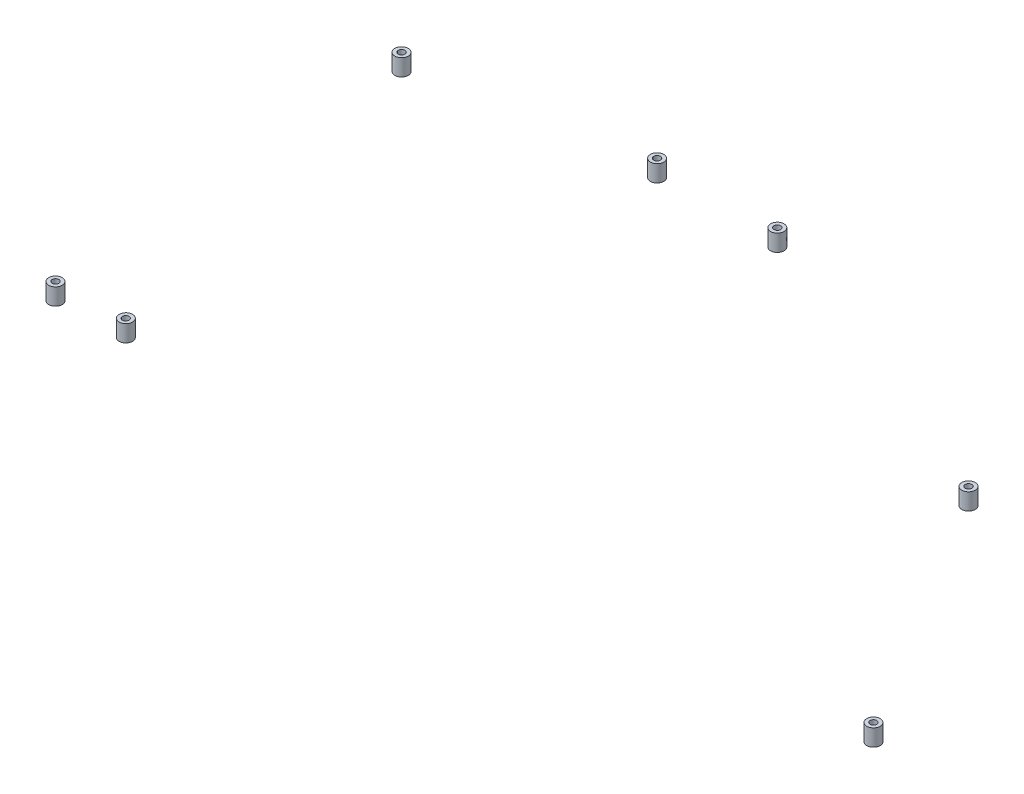
from build123d import *

# Parameters (mm, degrees)
SZKIC1_R                      = 4
SZKIC1_R_2                    = 2
DODANIE_WYCI_GNI_CIE1_DEPTH   = 10
DODANIE_WYCI_GNI_CIE1_2_DEPTH = 10
DODANIE_WYCI_GNI_CIE1_3_DEPTH = 10
SZKIC1_R_3                    = 3.999999999
DODANIE_WYCI_GNI_CIE1_4_DEPTH = 10
DODANIE_WYCI_GNI_CIE1_5_DEPTH = 10
DODANIE_WYCI_GNI_CIE1_6_DEPTH = 10
DODANIE_WYCI_GNI_CIE1_7_DEPTH = 10


with BuildPart() as part:
    # Szkic1 → Dodanie-wyciągnięcie1 (new body)
    with BuildSketch(Plane(origin=(0, 455.3, 0), x_dir=(1, 0, 0), z_dir=(0, 1, 0))):
        with Locations((-557.500474948, -428.076388532)):
            Circle(SZKIC1_R)
        with Locations((-557.500474948, -428.045174827)):
            Circle(SZKIC1_R_2, mode=Mode.SUBTRACT)
    extrude(amount=-DODANIE_WYCI_GNI_CIE1_DEPTH)


with BuildPart() as body_2:
    # Szkic1 → Dodanie-wyci_gni_cie1 2 (new body)
    with BuildSketch(Plane(origin=(0, 455.3, 0), x_dir=(1, 0, 0), z_dir=(0, 1, 0))):
        with Locations((-517.500474948, -426.079389265)):
            Circle(SZKIC1_R)
        with Locations((-517.500474948, -426.174740182)):
            Circle(SZKIC1_R_2, mode=Mode.SUBTRACT)
    extrude(amount=-DODANIE_WYCI_GNI_CIE1_2_DEPTH)


with BuildPart() as body_3:
    # Szkic1 → Dodanie-wyci_gni_cie1 3 (new body)
    with BuildSketch(Plane(origin=(0, 455.3, 0), x_dir=(1, 0, 0), z_dir=(0, 1, 0))):
        with Locations((-85.513533731, -411.920534849)):
            Circle(SZKIC1_R)
        with Locations((-85.513533731, -411.920534849)):
            Circle(SZKIC1_R_2, mode=Mode.SUBTRACT)
    extrude(amount=-DODANIE_WYCI_GNI_CIE1_3_DEPTH)


with BuildPart() as body_4:
    # Szkic1 → Dodanie-wyci_gni_cie1 4 (new body)
    with BuildSketch(Plane(origin=(0, 455.3, 0), x_dir=(1, 0, 0), z_dir=(0, 1, 0))):
        with Locations((-179.166238959, -261.544556892)):
            Circle(SZKIC1_R_3)
        with Locations((-179.166238959, -261.544556892)):
            Circle(SZKIC1_R_2, mode=Mode.SUBTRACT)
    extrude(amount=-DODANIE_WYCI_GNI_CIE1_4_DEPTH)


with BuildPart() as body_5:
    # Szkic1 → Dodanie-wyci_gni_cie1 5 (new body)
    with BuildSketch(Plane(origin=(0, 455.3, 0), x_dir=(1, 0, 0), z_dir=(0, 1, 0))):
        with Locations((-369.907883248, -184.906368669)):
            Circle(SZKIC1_R)
        with Locations((-369.907883248, -184.906368669)):
            Circle(SZKIC1_R_2, mode=Mode.SUBTRACT)
    extrude(amount=-DODANIE_WYCI_GNI_CIE1_5_DEPTH)


with BuildPart() as body_6:
    # Szkic1 → Dodanie-wyci_gni_cie1 6 (new body)
    with BuildSketch(Plane(origin=(0, 455.3, 0), x_dir=(1, 0, 0), z_dir=(0, 1, 0))):
        with Locations((-441.66371711, -184.906368669)):
            Circle(SZKIC1_R)
        with Locations((-441.66371711, -184.906368669)):
            Circle(SZKIC1_R_2, mode=Mode.SUBTRACT)
    extrude(amount=-DODANIE_WYCI_GNI_CIE1_6_DEPTH)


with BuildPart() as body_7:
    # Szkic1 → Dodanie-wyci_gni_cie1 7 (new body)
    with BuildSketch(Plane(origin=(0, 455.3, 0), x_dir=(1, 0, 0), z_dir=(0, 1, 0))):
        with Locations((-572.687982615, -206.365683114)):
            Circle(SZKIC1_R)
        with Locations((-572.687982615, -206.365683114)):
            Circle(SZKIC1_R_2, mode=Mode.SUBTRACT)
    extrude(amount=-DODANIE_WYCI_GNI_CIE1_7_DEPTH)


solid = Compound([part.part, body_2.part, body_3.part, body_4.part, body_5.part, body_6.part, body_7.part])
